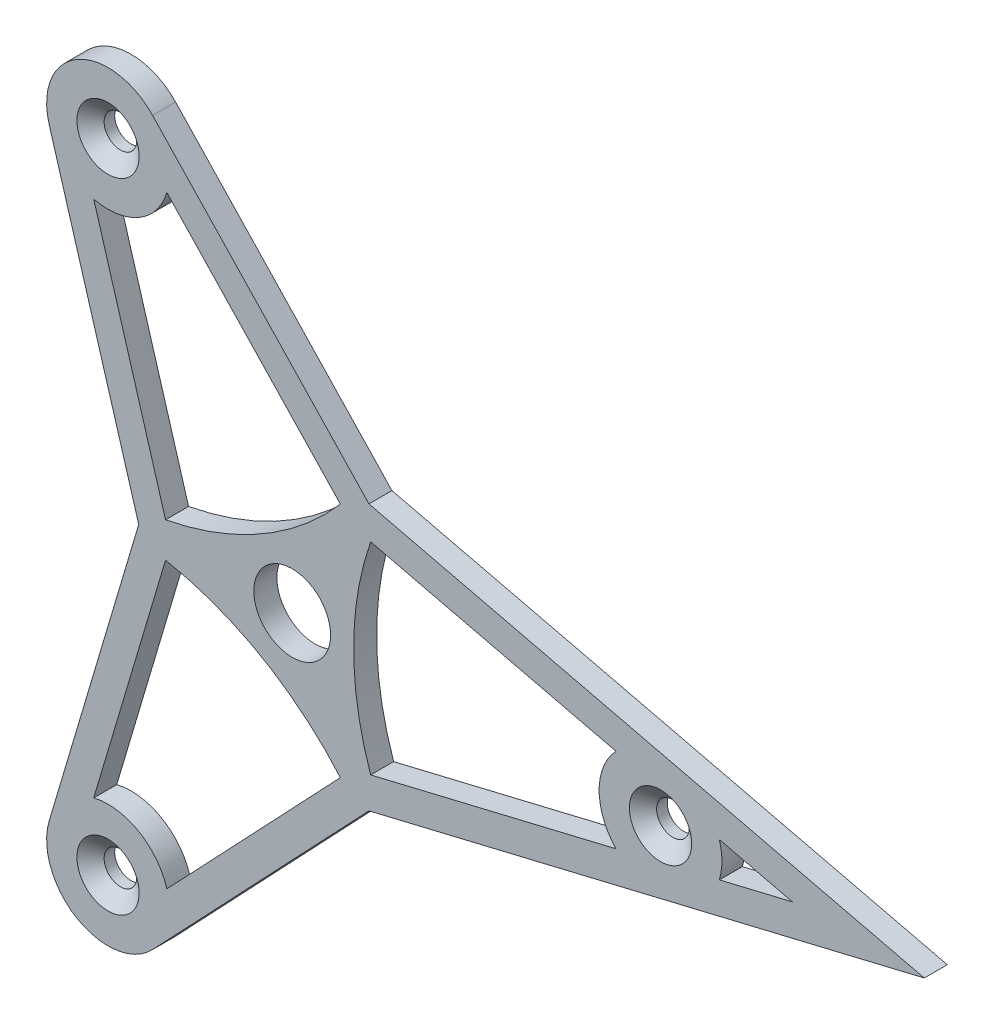
from build123d import *

# Parameters (mm, degrees)
SKETCH1_R                                   = 7.9375
BOSS_EXTRUDE1_DEPTH                         = 4.7625
CSK_FOR_1_4_FLAT_HEAD_MACHINE_SCREW_2_COUNT = 2
CSK_FOR_1_4_FLAT_HEAD_MACHINE_SCREW_2_PITCH = 131.982271537
CSK_FOR_1_4_FLAT_HEAD_MACHINE_SCREW_3_COUNT = 2
CSK_FOR_1_4_FLAT_HEAD_MACHINE_SCREW_3_PITCH = 131.982271537


with BuildPart() as part:
    # Sketch1 → Boss-Extrude1 (new body)
    with BuildSketch(Plane.XY):
        with BuildLine():
            Line((-31.75, 0), (-50.274457233, 62.375531935))
            ThreePointArc((-50.274457233, 62.375531935), (-44.45, 76.989658396), (-28.881566614, 74.726723093))
            Line((-28.881566614, 74.726723093), (15.875, 27.49630657))
            Line((15.875, 27.49630657), (78.9111987, 12.409785423))
            Line((78.9111987, 12.409785423), (130.763159277, 0))
            Line((130.763159277, 0), (79.156023847, -12.351191158))
            Line((79.156023847, -12.351191158), (15.875, -27.49630657))
            Line((15.875, -27.49630657), (-28.881566614, -74.726723093))
            ThreePointArc((-28.881566614, -74.726723093), (-44.45, -76.989658396), (-50.274457233, -62.375531935))
            Line((-50.274457233, -62.375531935), (-31.75, 0))
        make_face()
        Circle(SKETCH1_R, mode=Mode.SUBTRACT)
        with BuildLine():
            Line((9.968214912, 24.497802386), (-25.925542767, 62.375531935))
            ThreePointArc((-25.925542767, 62.375531935), (-31.75, 54.99261314), (-41.056023847, 53.639944611))
            Line((-41.056023847, 53.639944611), (-26.199826659, 3.616173849))
            ThreePointArc((-26.199826659, 3.616173849), (-6.35, 10.998522628), (9.968214912, 24.497802386))
        make_face(mode=Mode.SUBTRACT)
        with BuildLine():
            Line((16.231611747, 20.881628537), (66.981566614, 8.735587325))
            ThreePointArc((66.981566614, 8.735587325), (63.5, 0), (66.981566614, -8.735587325))
            Line((66.981566614, -8.735587325), (16.231611747, -20.881628537))
            ThreePointArc((16.231611747, -20.881628537), (12.7, 0), (16.231611747, 20.881628537))
        make_face(mode=Mode.SUBTRACT)
        with BuildLine():
            Line((88.374457233, 3.615603833), (103.481579639, 0))
            Line((103.481579639, 0), (88.374457233, -3.615603833))
            ThreePointArc((88.374457233, -3.615603833), (88.9, 0), (88.374457233, 3.615603833))
        make_face(mode=Mode.SUBTRACT)
        with BuildLine():
            Line((9.968214912, -24.497802386), (-25.925542767, -62.375531935))
            ThreePointArc((-25.925542767, -62.375531935), (-31.75, -54.99261314), (-41.056023847, -53.639944611))
            Line((-41.056023847, -53.639944611), (-26.199826659, -3.616173849))
            ThreePointArc((-26.199826659, -3.616173849), (-6.35, -10.998522628), (9.968214912, -24.497802386))
        make_face(mode=Mode.SUBTRACT)
    extrude(amount=-BOSS_EXTRUDE1_DEPTH)

    # Sketch3 → CSK for 1/4 Flat Head Machine Screw (100)1 (revolve, cut)
    with BuildSketch(Plane(origin=(76.2, 0, 0), x_dir=(0, -1, 0), z_dir=(1, 0, 0))):
        Polygon((0, 0), (0, 4.7625), (3.3782, 4.7625), (3.3782, 2.568232241), (6.4389, 0), align=None)
    csk_for_1_4_flat_head_machine_screw_100 = revolve(axis=Axis((76.2, 0, 6.35), (0, 0, -1)), mode=Mode.SUBTRACT)

    # CSK for 1_4 Flat Head Machine Screw  2: CSK for 1/4 Flat Head Machine Screw (100)1 ×2
    with Locations(*[Vector(-0.866025404, 0.5, 0) * (i * CSK_FOR_1_4_FLAT_HEAD_MACHINE_SCREW_2_PITCH) for i in range(1, CSK_FOR_1_4_FLAT_HEAD_MACHINE_SCREW_2_COUNT)]):
        add(csk_for_1_4_flat_head_machine_screw_100, mode=Mode.SUBTRACT)

    # CSK for 1_4 Flat Head Machine Screw  3: CSK for 1/4 Flat Head Machine Screw (100)1 ×2
    with Locations(*[Vector(-0.866025404, -0.5, 0) * (i * CSK_FOR_1_4_FLAT_HEAD_MACHINE_SCREW_3_PITCH) for i in range(1, CSK_FOR_1_4_FLAT_HEAD_MACHINE_SCREW_3_COUNT)]):
        add(csk_for_1_4_flat_head_machine_screw_100, mode=Mode.SUBTRACT)


solid = part.part
